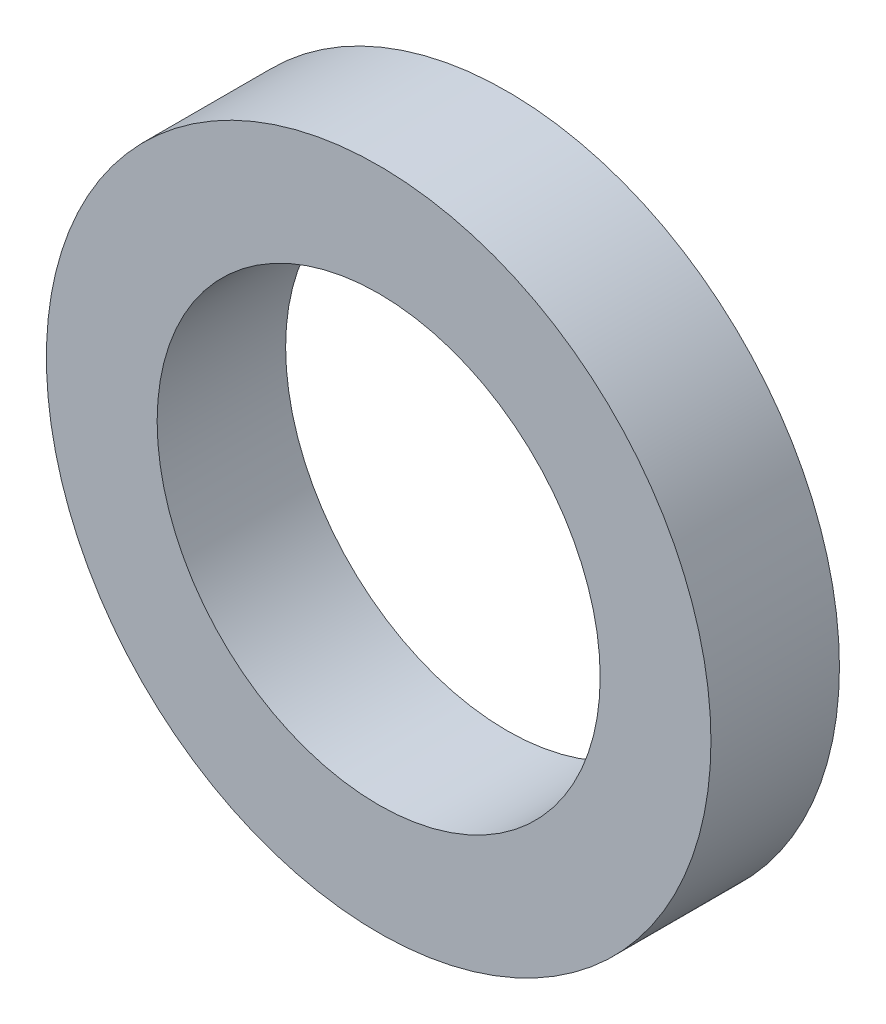
from build123d import *

# Parameters (mm, degrees)
SKETCH1_R           = 9.525
SKETCH1_R_2         = 6.35
BOSS_EXTRUDE1_DEPTH = 3.683


with BuildPart() as part:
    # Sketch1 → Boss-Extrude1 (new body)
    with BuildSketch(Plane.XY):
        Circle(SKETCH1_R)
        Circle(SKETCH1_R_2, mode=Mode.SUBTRACT)
    extrude(amount=BOSS_EXTRUDE1_DEPTH)


solid = part.part
